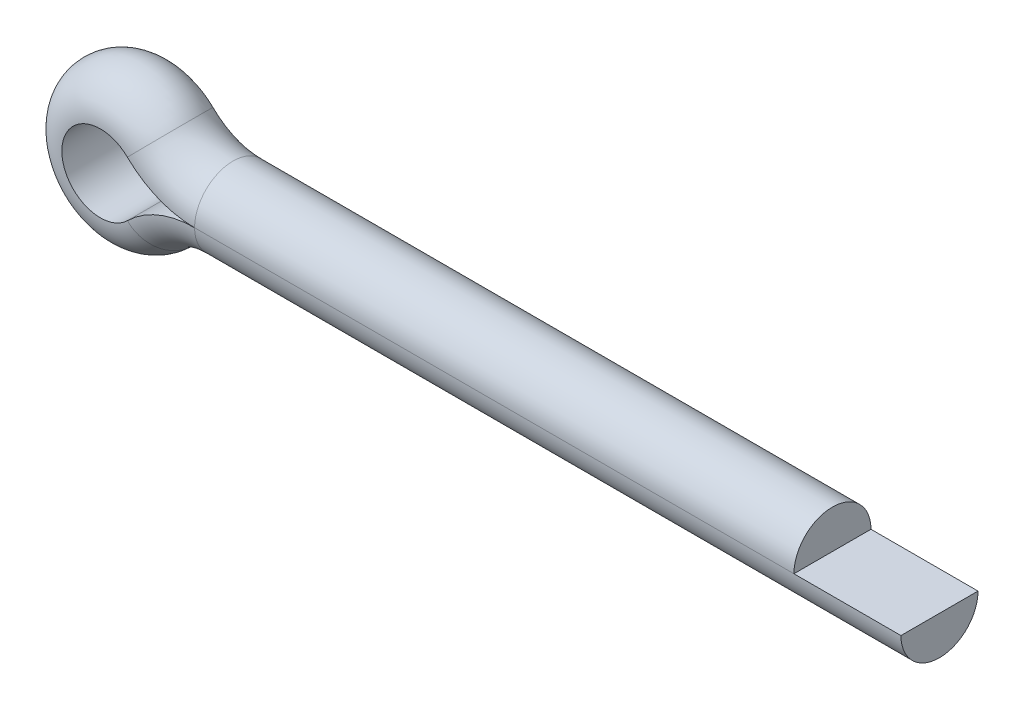
from build123d import *


with BuildPart() as part:
    # Body: sweep along a path in PathSke
    with BuildLine(Plane(origin=(1.207969362, 1.807969362, 0), x_dir=(0, 1, 0), z_dir=(0, 0, 1))) as body_path:
        Line((-0.907969362, -16.792030638), (-0.907969362, -2.792030638))
        ThreePointArc((-0.907969362, -2.792030638), (-0.808285009, -2.285083328), (-0.524075557, -1.853623558))
        ThreePointArc((-0.524075557, -1.853623558), (-1.807969362, 1.207969362), (-3.091863167, -1.853623558))
        ThreePointArc((-3.091863167, -1.853623558), (-2.807653715, -2.285083328), (-2.707969362, -2.792030638))
        Line((-2.707969362, -2.792030638), (-2.707969362, -19.292030638))
    # SectionSke → Body (sweep)
    with BuildSketch(Plane(origin=(18, 0.15, 0.15), x_dir=(0, 1, 0), z_dir=(1, 0, 0))):
        with BuildLine():
            Line((-0.15, -1.05), (-0.15, 0.75))
            ThreePointArc((-0.15, 0.75), (0.75, -0.15), (-0.15, -1.05))
        make_face()
    sweep(path=body_path.line)


solid = part.part
